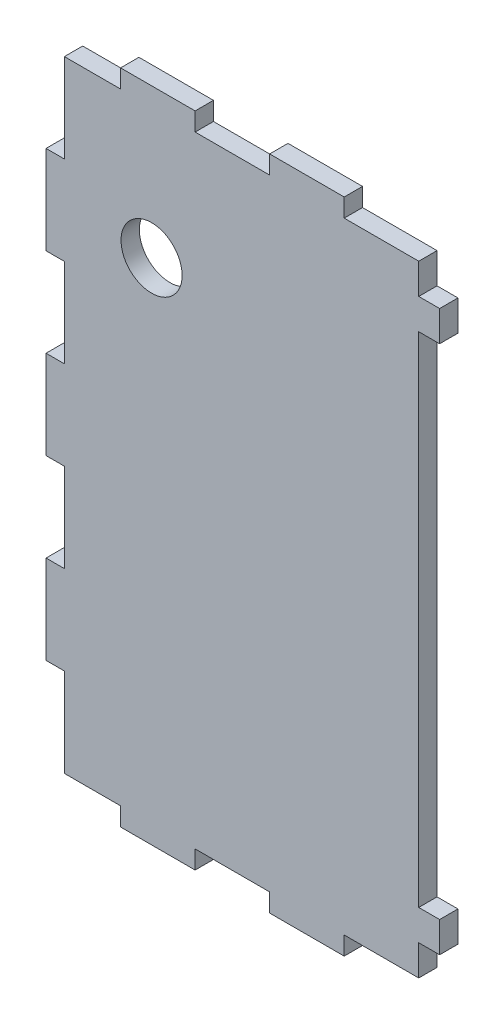
from build123d import *

# Parameters (mm, degrees)
CROQUIS1_R              = 5
SALIENTE_EXTRUIR1_DEPTH = 3


with BuildPart() as part:
    # Croquis1 → Saliente-Extruir1 (new body)
    with BuildSketch(Plane.XY):
        Polygon((174.557067775, -156.100114598), (165.357067775, -156.100114598), (165.357067775, -170.615828883), (162.357067775, -170.615828883), (162.357067775, -185.131543169), (165.357067775, -185.131543169), (165.357067775, -199.647257455), (162.357067775, -199.647257455), (162.357067775, -214.162971741), (165.357067775, -214.162971741), (165.357067775, -228.678686026), (162.357067775, -228.678686026), (162.357067775, -243.194400312), (165.357067775, -243.194400312), (165.357067775, -257.710114598), (174.557067775, -257.710114598), (174.557067775, -260.710114598), (186.757067775, -260.710114598), (186.757067775, -257.710114598), (198.957067775, -257.710114598), (198.957067775, -260.710114598), (211.157067775, -260.710114598), (211.157067775, -257.710114598), (223.357067775, -257.710114598), (223.357067775, -252.710114598), (226.776809623, -252.710114598), (226.776809623, -247.710114598), (223.357067775, -247.710114598), (223.357067775, -170.615828883), (223.357067775, -166.100114598), (226.776809623, -166.100114598), (226.776809623, -161.100114598), (223.357067775, -161.100114598), (223.357067775, -156.100114598), (211.157067775, -156.100114598), (211.157067775, -153.100114598), (198.957067775, -153.100114598), (198.957067775, -156.100114598), (186.757067775, -156.100114598), (186.757067775, -153.100114598), (174.557067775, -153.100114598), align=None)
        with Locations((179.628110515, -177.498140377)):
            Circle(CROQUIS1_R, mode=Mode.SUBTRACT)
    extrude(amount=SALIENTE_EXTRUIR1_DEPTH)


solid = part.part
